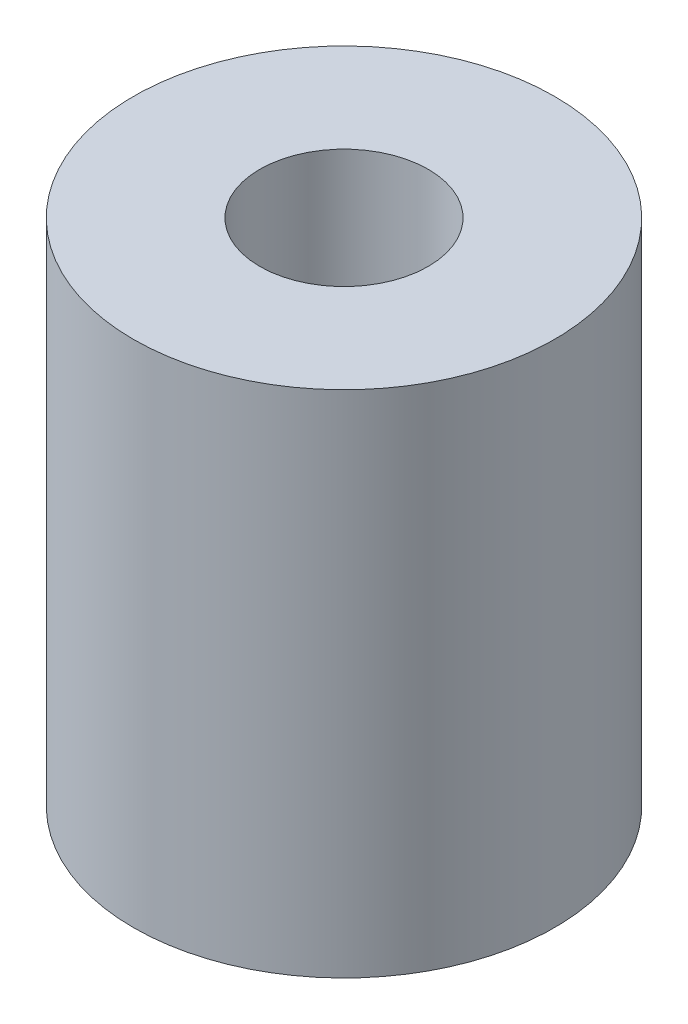
from build123d import *

# Parameters (mm, degrees)
SKETCH1_R           = 5
SKETCH1_R_2         = 2
BOSS_EXTRUDE1_DEPTH = 6.05


with BuildPart() as part:
    # Sketch1 → Boss-Extrude1 (new body, symmetric)
    with BuildSketch(Plane(origin=(0, 0, 0), x_dir=(1, 0, 0), z_dir=(0, 1, 0))):
        Circle(SKETCH1_R)
        Circle(SKETCH1_R_2, mode=Mode.SUBTRACT)
    extrude(amount=BOSS_EXTRUDE1_DEPTH, both=True)


solid = part.part
